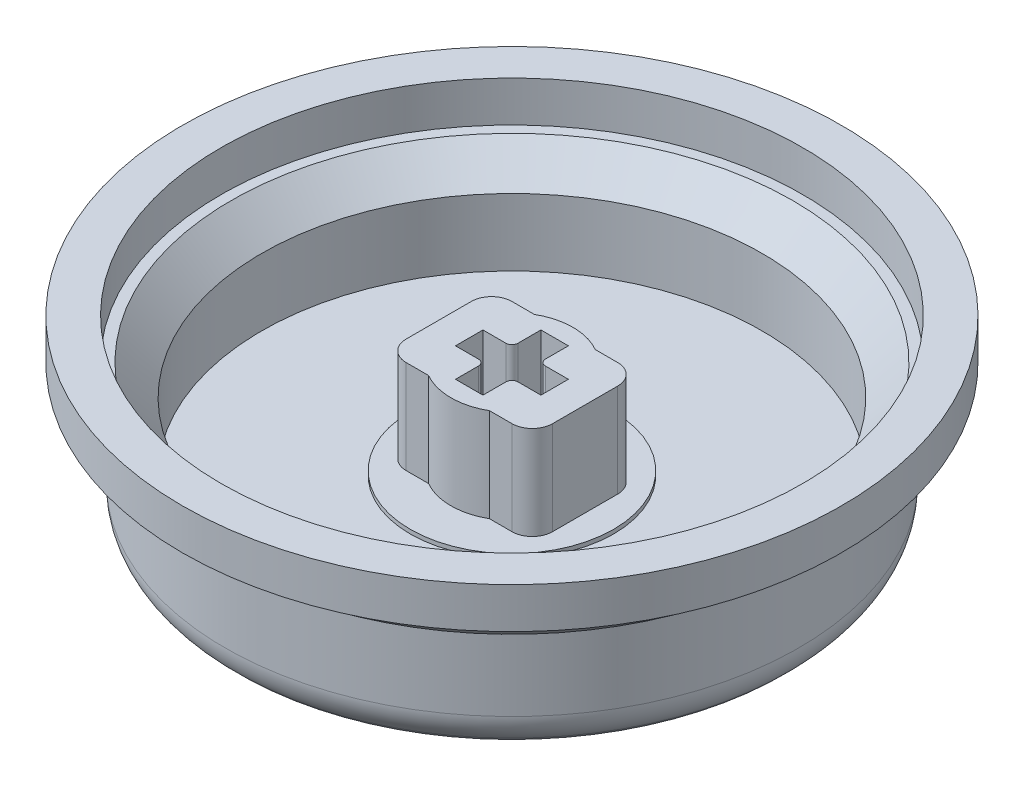
from build123d import *

# Parameters (mm, degrees)
SKETCH1_R           = 14.1
BUTTON_TOP_DEPTH    = 1.8
SKETCH2_R           = 14.1
SKETCH2_R_2         = 12.3
BUTTON_WALLS_DEPTH  = 4.8
SKETCH5_R           = 5
OFFSET_2_DEPTH      = 0.2
STEM_START          = 0.2
STEM_HOUSING_DEPTH  = 4.6
CHAMFER1_SIZE       = 1.5
FILLET2_R           = 1
SKETCH8_R           = 16.2
SKETCH8_R_2         = 14.3
BOSS_EXTRUDE1_DEPTH = 2


with BuildPart() as part:
    # Sketch1 → button top (new body)
    with BuildSketch(Plane(origin=(0, 0, 0), x_dir=(1, 0, 0), z_dir=(0, 1, 0))):
        Circle(SKETCH1_R)
    extrude(amount=BUTTON_TOP_DEPTH)

    # Sketch2 → button walls (add)
    with BuildSketch(Plane(origin=(0, 1.8, 0), x_dir=(1, 0, 0), z_dir=(0, 1, 0))):
        Circle(SKETCH2_R)
        Circle(SKETCH2_R_2, mode=Mode.SUBTRACT)
    extrude(amount=BUTTON_WALLS_DEPTH)

    # Sketch5 → offset 2 (add)
    with BuildSketch(Plane(origin=(0, 1.8, 0), x_dir=(1, 0, 0), z_dir=(0, 1, 0))):
        Circle(SKETCH5_R)
    extrude(amount=OFFSET_2_DEPTH)

    # Sketch3 → stem housing (add)
    with BuildSketch(Plane(origin=(0, 1.8, 0), x_dir=(1, 0, 0), z_dir=(0, 1, 0)).offset(STEM_START)):
        with BuildLine():
            Line((-3.6, 2.6), (-3.6, -2.6))
            Line((-3.6, -2.6), (-1.496662955, -2.6))
            ThreePointArc((-1.496662955, -2.6), (-3, 0), (-1.496662955, 2.6))
            Line((-1.496662955, 2.6), (-3.6, 2.6))
        make_face()
        with BuildLine():
            ThreePointArc((-1.496662955, 2.6), (-3, 0), (-1.496662955, -2.6))
            Line((-1.496662955, -2.6), (1.496662955, -2.6))
            ThreePointArc((1.496662955, -2.6), (2.597112711, -1.501667596), (3, 0))
            ThreePointArc((3, 0), (2.597112711, 1.501667596), (1.496662955, 2.6))
            Line((1.496662955, 2.6), (-1.496662955, 2.6))
        make_face()
        with BuildLine():
            ThreePointArc((-0.975, 0.675), (-0.762867966, 0.762867966), (-0.675, 0.975))
            Line((-0.675, 0.975), (-0.675, 2.1))
            Line((-0.675, 2.1), (0.675, 2.1))
            Line((0.675, 2.1), (0.675, 0.975))
            ThreePointArc((0.675, 0.975), (0.762867966, 0.762867966), (0.975, 0.675))
            Line((0.975, 0.675), (2.1, 0.675))
            Line((2.1, 0.675), (2.1, -0.675))
            Line((2.1, -0.675), (0.975, -0.675))
            ThreePointArc((0.975, -0.675), (0.762867966, -0.762867966), (0.675, -0.975))
            Line((0.675, -0.975), (0.675, -2.1))
            Line((0.675, -2.1), (-0.675, -2.1))
            Line((-0.675, -2.1), (-0.675, -0.975))
            ThreePointArc((-0.675, -0.975), (-0.762867966, -0.762867966), (-0.975, -0.675))
            Line((-0.975, -0.675), (-2.1, -0.675))
            Line((-2.1, -0.675), (-2.1, 0.675))
            Line((-2.1, 0.675), (-0.975, 0.675))
        make_face(mode=Mode.SUBTRACT)
        with BuildLine():
            ThreePointArc((3, 0), (2.597112711, -1.501667596), (1.496662955, -2.6))
            Line((1.496662955, -2.6), (3.6, -2.6))
            Line((3.6, -2.6), (3.6, 2.6))
            Line((3.6, 2.6), (1.496662955, 2.6))
            ThreePointArc((1.496662955, 2.6), (2.597112711, 1.501667596), (3, 0))
        make_face()
        with BuildLine():
            ThreePointArc((1.496662955, 2.6), (0, 3), (-1.496662955, 2.6))
            Line((-1.496662955, 2.6), (1.496662955, 2.6))
        make_face()
        with BuildLine():
            Line((1.496662955, -2.6), (-1.496662955, -2.6))
            ThreePointArc((-1.496662955, -2.6), (0, -3), (1.496662955, -2.6))
        make_face()
    extrude(amount=STEM_HOUSING_DEPTH)

    # Chamfer1
    chamfer1_edges = [part.edges().sort_by_distance(p)[0] for p in [
        (-12.3, 6.6, 0),
    ]]
    chamfer(chamfer1_edges, length=CHAMFER1_SIZE)

    # Fillet2
    fillet2_edges = [part.edges().sort_by_distance(p)[0] for p in [
        (-3.6, 4.3, -2.6),
        (-3.6, 4.3, 2.6),
        (3.6, 4.3, 2.6),
        (3.6, 4.3, -2.6),
    ]]
    fillet(fillet2_edges, radius=FILLET2_R)

    # Sketch6 → Cut-Revolve1 (revolve, cut)
    with BuildSketch(Plane.XY):
        with BuildLine():
            Line((-13.361522369, 0), (-13.561522369, 0.2))
            ThreePointArc((-13.561522369, 0.2), (-13.960054223, 0.79644507), (-14.1, 1.5))
            Line((-14.1, 1.5), (-14.1, 0))
            Line((-14.1, 0), (-13.361522369, 0))
        make_face()
    revolve(axis=Axis((0, 0, 0), (0, 1, 0)), mode=Mode.SUBTRACT)

    # Sketch7 → Revolve1 (revolve)
    with BuildSketch(Plane.XY):
        Polygon((14.1, 6.6), (15.7, 6.6), (14.1, 5), align=None)
    revolve(axis=Axis((0, 0, 0), (0, 1, 0)))

    # Sketch8 → Boss-Extrude1 (add)
    with BuildSketch(Plane(origin=(0, 6.6, 0), x_dir=(1, 0, 0), z_dir=(0, 1, 0))):
        Circle(SKETCH8_R)
        Circle(SKETCH8_R_2, mode=Mode.SUBTRACT)
    extrude(amount=BOSS_EXTRUDE1_DEPTH)


solid = part.part
